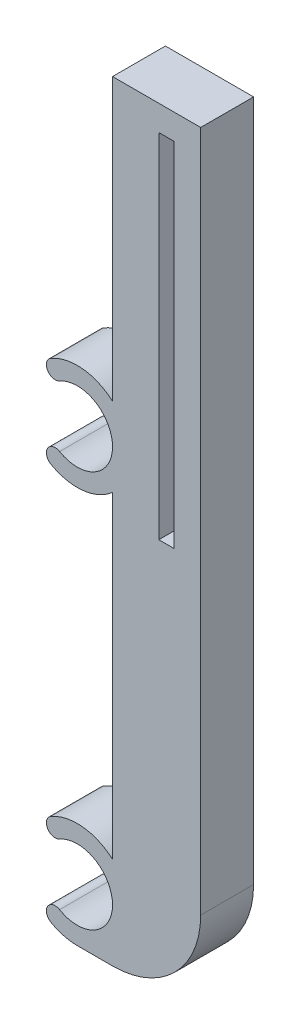
from build123d import *

# Parameters (mm, degrees)
BOSS_EXTRUDE_BASE_DEPTH = 6
SKETCH4_W               = 1.75
SKETCH4_H               = 40
CUT_EXTRUDE_SLOT_DEPTH  = 4.5


with BuildPart() as part:
    # Sketch1 → Boss-Extrude-Base (new body)
    with BuildSketch(Plane.XY):
        with BuildLine():
            Line((17.5, 87.375), (17.5, 10))
            ThreePointArc((17.5, 10), (14.571067812, 2.928932188), (7.5, 0))
            Line((7.5, 0), (3.5, 0))
            ThreePointArc((3.5, 0), (1.947085729, 0.204445042), (0.5, 0.803847577))
            ThreePointArc((0.5, 0.803847577), (0.133974596, 2.169872981), (1.5, 2.535898385))
            ThreePointArc((1.5, 2.535898385), (7.5, 6), (1.5, 9.464101615))
            ThreePointArc((1.5, 9.464101615), (0.133974596, 9.830127019), (0.5, 11.196152423))
            ThreePointArc((0.5, 11.196152423), (4.117292444, 11.968161362), (7.5, 10.472135955))
            Line((7.5, 10.472135955), (7.5, 46.527864045))
            ThreePointArc((7.5, 46.527864045), (4.117292444, 45.031838638), (0.5, 45.803847577))
            ThreePointArc((0.5, 45.803847577), (0.133974596, 47.169872981), (1.5, 47.535898385))
            ThreePointArc((1.5, 47.535898385), (7.5, 51), (1.5, 54.464101615))
            ThreePointArc((1.5, 54.464101615), (0.133974596, 54.830127019), (0.5, 56.196152423))
            ThreePointArc((0.5, 56.196152423), (4.117292444, 56.968161362), (7.5, 55.472135955))
            Line((7.5, 55.472135955), (7.5, 87.375))
            Line((7.5, 87.375), (17.5, 87.375))
        make_face()
    extrude(amount=BOSS_EXTRUDE_BASE_DEPTH)

    # Sketch4 → Cut-Extrude-Slot (cut)
    with BuildSketch(Plane.XY.offset(6)):
        with Locations((13.625, 64.5)):
            Rectangle(SKETCH4_W, SKETCH4_H)
    extrude(amount=-CUT_EXTRUDE_SLOT_DEPTH, mode=Mode.SUBTRACT)


solid = part.part
